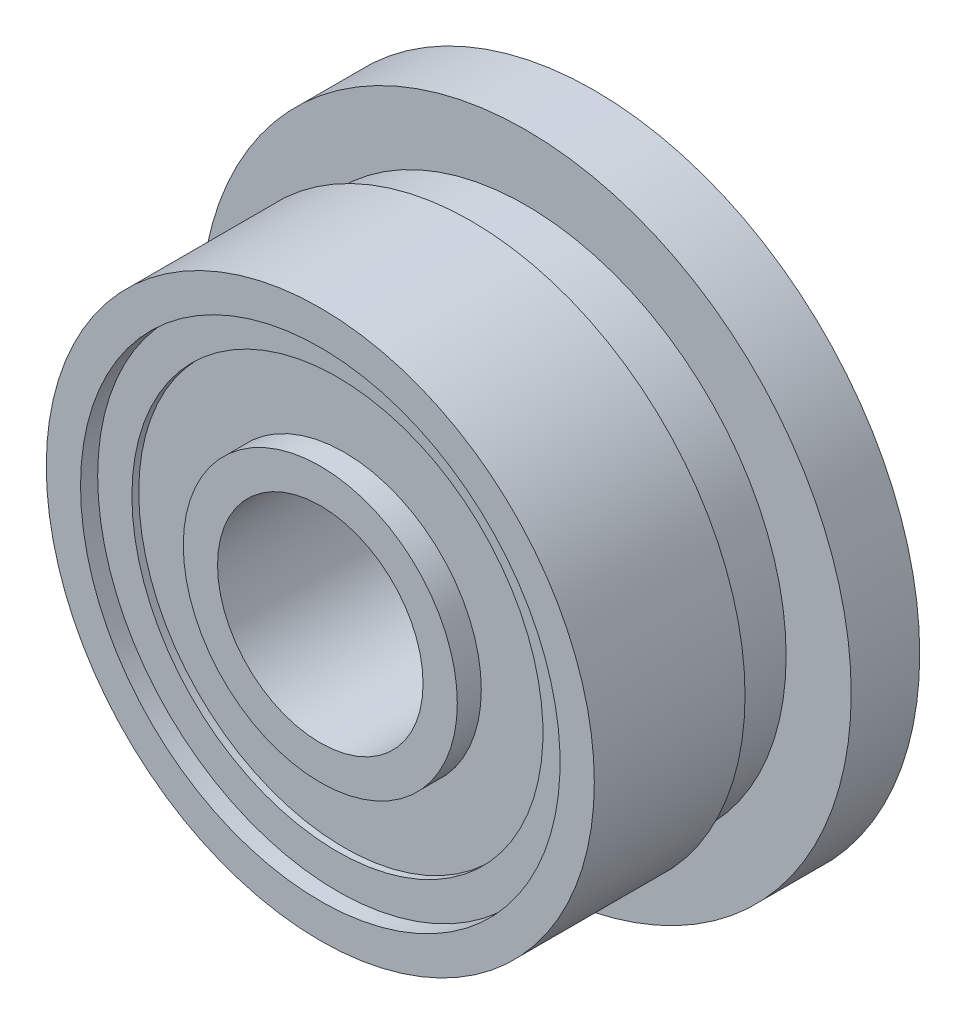
from build123d import *

# Parameters (mm, degrees)
SCHIZZO1_R                   = 4
ESTRUSIONE_ESTRUSIONE1_DEPTH = 4
SCHIZZO2_R                   = 1.5
TAGLIO_ESTRUSIONE1_DEPTH     = 5
SCHIZZO3_R                   = 3.5
SCHIZZO3_R_2                 = 2
TAGLIO_ESTRUSIONE2_DEPTH     = 0.25
SCHIZZO4_R                   = 3
SCHIZZO4_R_2                 = 2
TAGLIO_ESTRUSIONE3_DEPTH     = 0.1
SCHIZZO5_R                   = 4.75
SCHIZZO5_R_2                 = 4
ESTRUSIONE_ESTRUSIONE2_DEPTH = 1
SCHIZZO6_W                   = 0.2
SCHIZZO6_H                   = 0.8


with BuildPart() as part:
    # Schizzo1 → Estrusione-Estrusione1 (new body)
    with BuildSketch(Plane.XY):
        Circle(SCHIZZO1_R)
    extrude(amount=ESTRUSIONE_ESTRUSIONE1_DEPTH)

    # Schizzo2 → Taglio-Estrusione1 (cut, through all)
    with BuildSketch(Plane.XY.offset(4)):
        Circle(SCHIZZO2_R)
    extrude(amount=-TAGLIO_ESTRUSIONE1_DEPTH, mode=Mode.SUBTRACT)

    # Schizzo3 → Taglio-Estrusione2 (cut)
    with BuildSketch(Plane(origin=(0, 0, 0), x_dir=(-1, 0, 0), z_dir=(0, 0, -1))):
        Circle(SCHIZZO3_R)
        Circle(SCHIZZO3_R_2, mode=Mode.SUBTRACT)
    taglio_estrusione2 = extrude(amount=-TAGLIO_ESTRUSIONE2_DEPTH, mode=Mode.SUBTRACT)

    # Schizzo4 → Taglio-Estrusione3 (cut)
    with BuildSketch(Plane(origin=(0, 0, 0.25), x_dir=(-1, 0, 0), z_dir=(0, 0, -1))):
        Circle(SCHIZZO4_R)
        Circle(SCHIZZO4_R_2, mode=Mode.SUBTRACT)
    taglio_estrusione3 = extrude(amount=-TAGLIO_ESTRUSIONE3_DEPTH, mode=Mode.SUBTRACT)

    # Specchia1: Taglio-Estrusione2, Taglio-Estrusione3 across plane
    add(taglio_estrusione2.mirror(Plane.XY.offset(2)), mode=Mode.SUBTRACT)
    add(taglio_estrusione3.mirror(Plane.XY.offset(2)), mode=Mode.SUBTRACT)

    # Schizzo5 → Estrusione-Estrusione2 (add)
    with BuildSketch(Plane.XY):
        Circle(SCHIZZO5_R)
        Circle(SCHIZZO5_R_2, mode=Mode.SUBTRACT)
    extrude(amount=ESTRUSIONE_ESTRUSIONE2_DEPTH)

    # Schizzo6 → Taglia-Rivoluzione1 (revolve, cut)
    with BuildSketch(Plane(origin=(0, 0, 0), x_dir=(1, 0, 0), z_dir=(0, 1, 0))):
        with Locations((3.9, -1.4)):
            Rectangle(SCHIZZO6_W, SCHIZZO6_H)
    revolve(axis=Axis((0, 0, 4), (0, 0, -1)), mode=Mode.SUBTRACT)


solid = part.part
